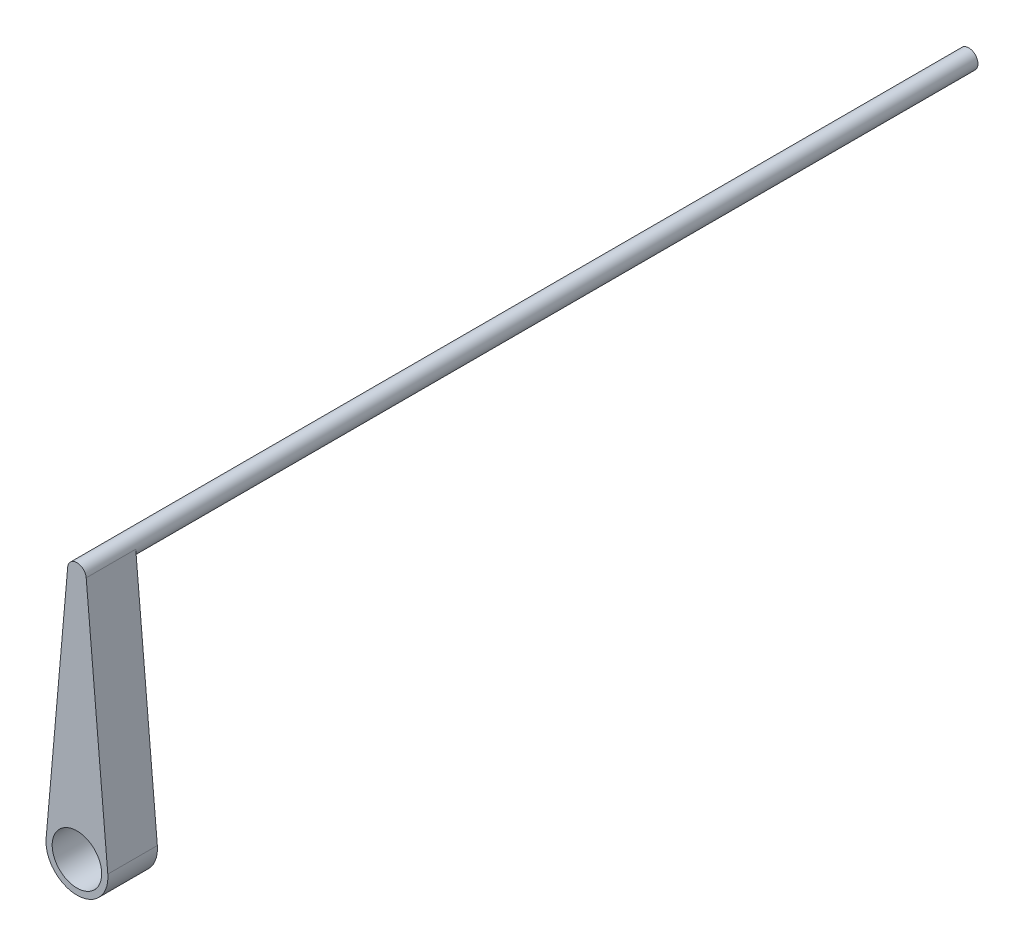
from build123d import *

# Parameters (mm, degrees)
IZIM1_R                          = 2
Y_KSEKLIK_EKSTR_ZYON1_DEPTH      = 4
Y_KSEKLIK_EKSTR_ZYON2_DEPTH      = 4
Y_KSEKLIK_EKSTR_ZYON2_DEPTH_BACK = 68


with BuildPart() as part:
    # Çizim1 → Yükseklik-Ekstrüzyon1 (new body)
    with BuildSketch(Plane.XY):
        with BuildLine():
            Line((2.490411299, 0.21875), (0.74712339, 20.065625))
            ThreePointArc((0.74712339, 20.065625), (0, 19.25), (-0.74712339, 20.065625))
            Line((-0.74712339, 20.065625), (-2.490411299, 0.21875))
            ThreePointArc((-2.490411299, 0.21875), (0, -2.5), (2.490411299, 0.21875))
        make_face()
        Circle(IZIM1_R, mode=Mode.SUBTRACT)
    extrude(amount=Y_KSEKLIK_EKSTR_ZYON1_DEPTH)

    # Çizim1<3> → Yükseklik-Ekstrüzyon2 (add, two sides: drawn at the far end of the back side and taken through both)
    with BuildSketch(Plane.XY.offset(-Y_KSEKLIK_EKSTR_ZYON2_DEPTH_BACK)):
        with BuildLine():
            ThreePointArc((0.74712339, 20.065625), (0, 20.75), (-0.74712339, 20.065625))
            ThreePointArc((-0.74712339, 20.065625), (-0.032844008, 19.250719498), (0.75, 20))
            ThreePointArc((0.75, 20), (0.749280502, 20.032844008), (0.74712339, 20.065625))
        make_face()
    extrude(amount=Y_KSEKLIK_EKSTR_ZYON2_DEPTH + Y_KSEKLIK_EKSTR_ZYON2_DEPTH_BACK)


solid = part.part
